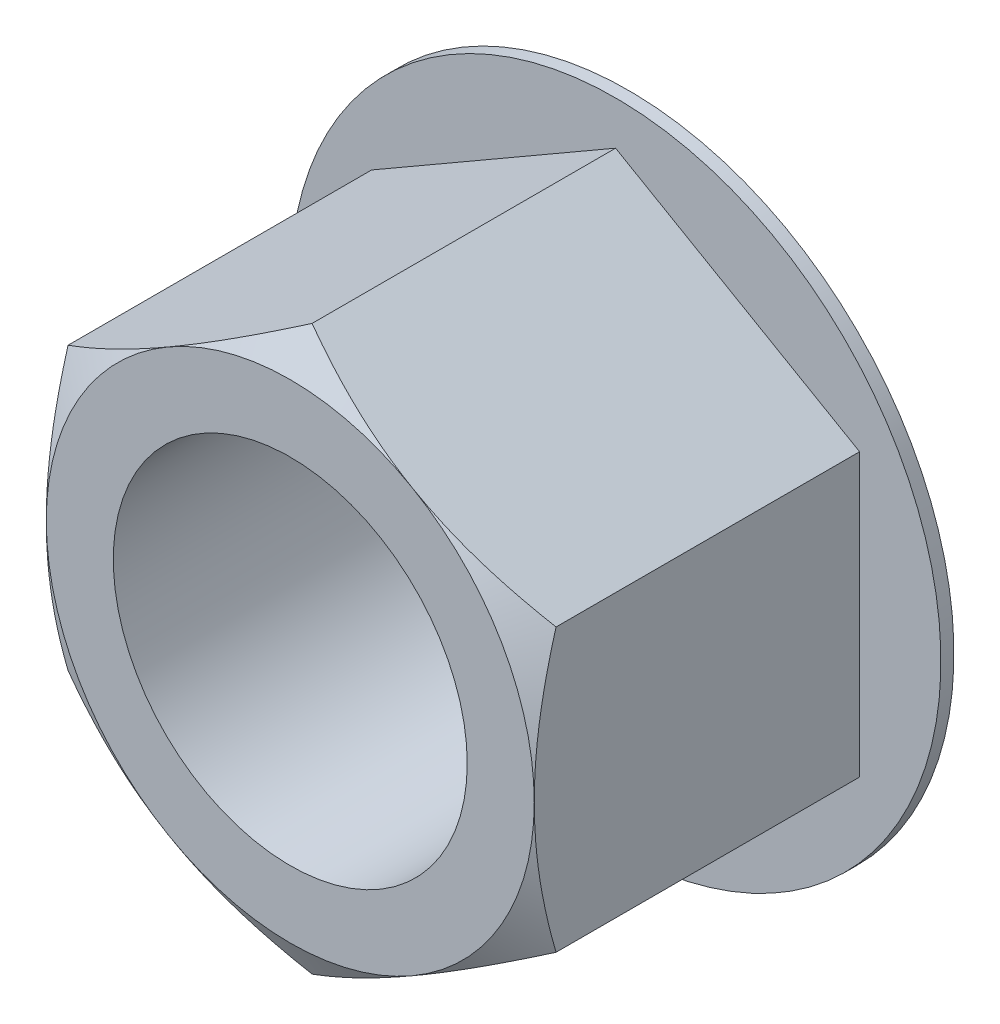
from build123d import *

# Parameters (mm, degrees)
EXTRUDE1_DEPTH           = 3.302
SKETCH2_OUTSIDE_W        = 41.061
SKETCH2_OUTSIDE_H        = 42.534
SKETCH2_OUTSIDE_R        = 4.7625
CUT_EXTRUDE1_DEPTH       = 7.604
CUT_EXTRUDE1_TAPER       = 60
SKETCH17_R               = 6.35
EXTRUDE3_DEPTH           = 0.254
F_5_16_24_TAPPED_HOLE1_D = 6.9088


with BuildPart() as part:
    # Sketch1 → Extrude1 (new body, symmetric)
    with BuildSketch(Plane.XY):
        Polygon((4.7625, -2.749630657), (4.7625, 2.749630657), (0, 5.499261314), (-4.7625, 2.749630657), (-4.7625, -2.749630657), (0, -5.499261314), align=None)
    extrude(amount=EXTRUDE1_DEPTH, both=True)

    # Sketch2 outside → Cut-Extrude1 (cut, through all)
    with BuildSketch(Plane.XY.offset(3.302)):
        with Locations((-0.0005, 0)):
            Rectangle(SKETCH2_OUTSIDE_W, SKETCH2_OUTSIDE_H)
        Circle(SKETCH2_OUTSIDE_R, mode=Mode.SUBTRACT)
    extrude(amount=-CUT_EXTRUDE1_DEPTH, taper=CUT_EXTRUDE1_TAPER, mode=Mode.SUBTRACT)

    # Sketch17 → Extrude3 (add)
    with BuildSketch(Plane(origin=(0, 0, -3.302), x_dir=(-1, 0, 0), z_dir=(0, 0, -1))):
        Circle(SKETCH17_R)
    extrude(amount=-EXTRUDE3_DEPTH)

    # 5/16-24 Tapped Hole1 (through all)
    with Locations(Plane.XY.offset(3.302)):
        with Locations((0, 0)):
            Hole(F_5_16_24_TAPPED_HOLE1_D / 2)


solid = part.part
